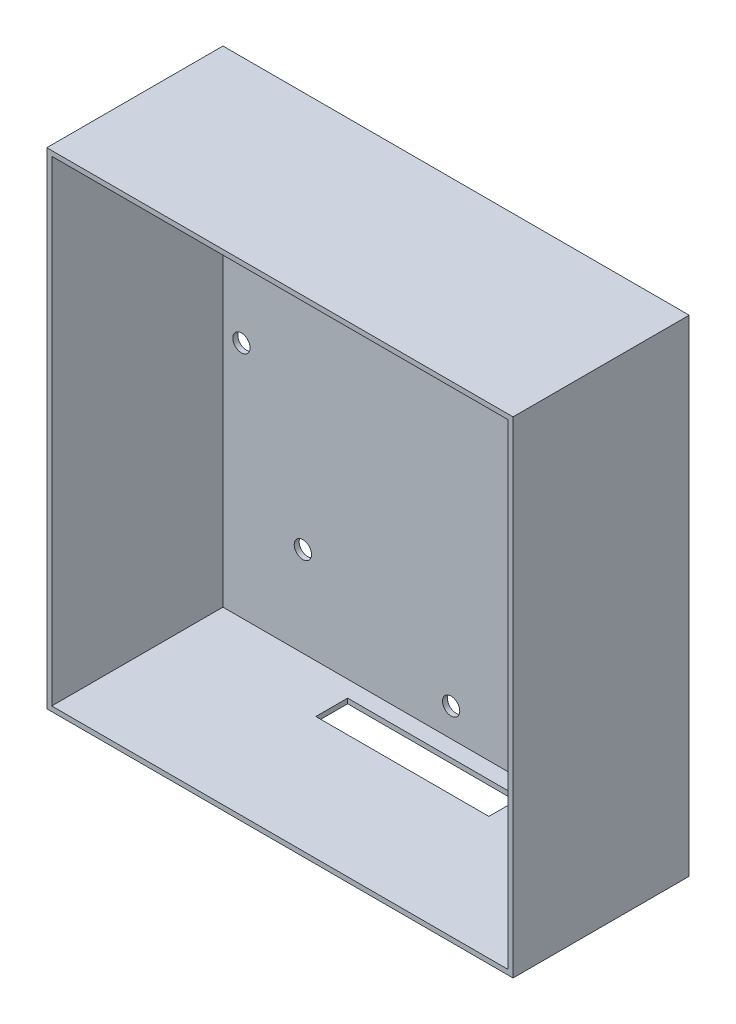
from build123d import *

# Parameters (mm, degrees)
SKETCH_2_W          = 94.5
SKETCH_2_H          = 98.5
EXTRUDE_1_DEPTH     = 35.7
SHELL_1_T           = -1
SKETCH_5_W          = 35.076830759
SKETCH_5_H          = 6.451639633
CUT_EXTRUDE_1_DEPTH = 2
SKETCH_3_R          = 1.75
CUT_EXTRUDE_2_DEPTH = 2


with BuildPart() as part:
    # 草图2 → 凸台-拉伸1 (new body)
    with BuildSketch(Plane.XY):
        with Locations((47.25, 49.25)):
            Rectangle(SKETCH_2_W, SKETCH_2_H)
    extrude(amount=EXTRUDE_1_DEPTH)

    # 抽壳1
    shell_1_openings = [part.faces().sort_by_distance(p)[0] for p in [
        (47.25, 49.25, 35.7),
    ]]
    offset(amount=SHELL_1_T, openings=shell_1_openings, kind=Kind.INTERSECTION)

    # 草图5 → 切除-拉伸1 (cut, through all)
    with BuildSketch(Plane(origin=(0, 1, 0), x_dir=(1, 0, 0), z_dir=(0, 1, 0))):
        with Locations((47.144981411, -7.555579656)):
            Rectangle(SKETCH_5_W, SKETCH_5_H)
    extrude(amount=-CUT_EXTRUDE_1_DEPTH, mode=Mode.SUBTRACT)

    # 草图3 → 切除-拉伸2 (cut, through all)
    with BuildSketch(Plane.XY.offset(1)):
        with Locations((4.75, 49.25)):
            Circle(SKETCH_3_R)
        with Locations((17.1979618, 19.1979618)):
            Circle(SKETCH_3_R)
        with Locations((47.25, 6.75)):
            Circle(SKETCH_3_R)
        with Locations((77.302038201, 19.1979618)):
            Circle(SKETCH_3_R)
        with Locations((89.75, 49.25)):
            Circle(SKETCH_3_R)
        with Locations((77.302038201, 79.3020382)):
            Circle(SKETCH_3_R)
        with Locations((47.25, 91.75)):
            Circle(SKETCH_3_R)
        with Locations((17.1979618, 79.3020382)):
            Circle(SKETCH_3_R)
    extrude(amount=-CUT_EXTRUDE_2_DEPTH, mode=Mode.SUBTRACT)


solid = part.part
